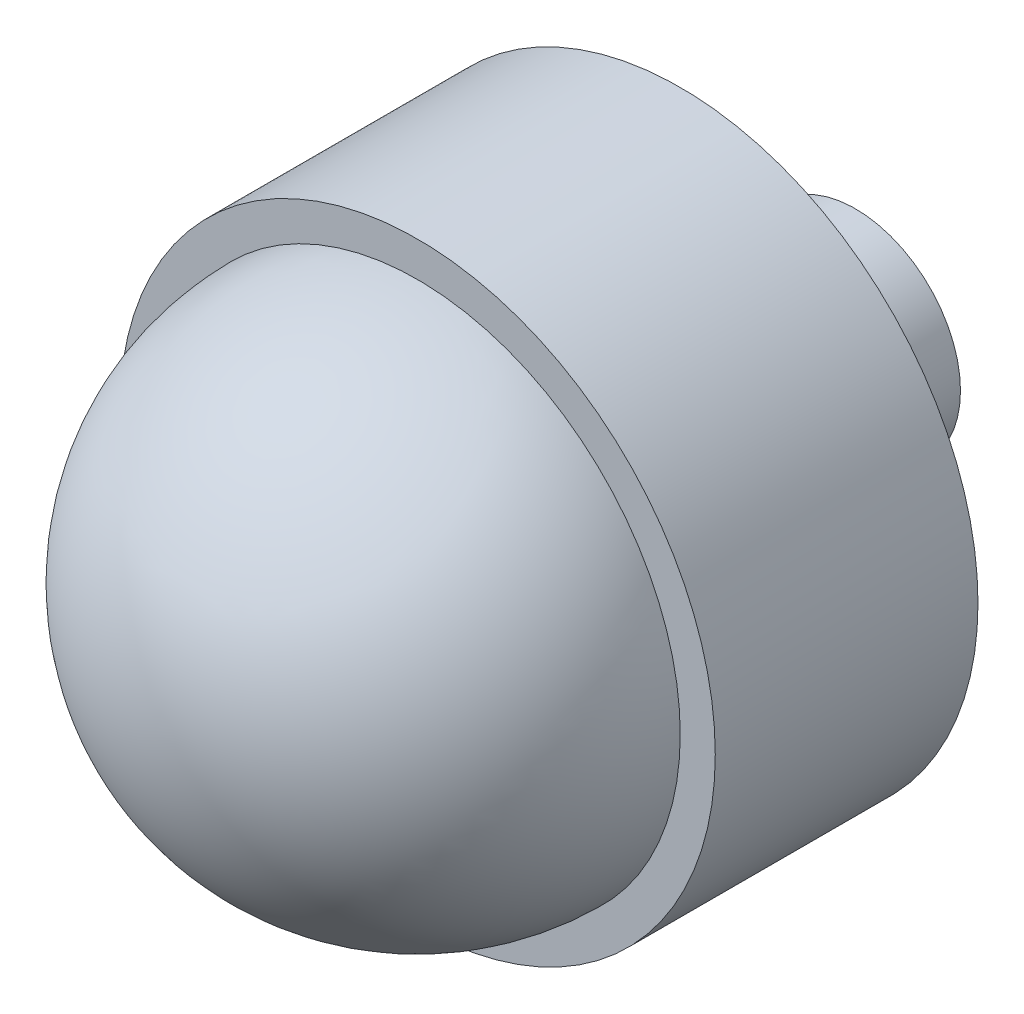
from build123d import *


with BuildPart() as part:
    # Sketch1 → Revolve6 (revolve)
    with BuildSketch(Plane(origin=(0, 0, 0), x_dir=(1, 0, 0), z_dir=(0, 1, 0))):
        with BuildLine():
            Line((0, 73.69930834), (6, 73.69930834))
            Line((6, 73.69930834), (6, 63.69930834))
            Line((6, 63.69930834), (17, 63.69930834))
            Line((17, 63.69930834), (17, 48.69930834))
            Line((17, 48.69930834), (15, 48.69930834))
            ThreePointArc((15, 48.69930834), (10.606601718, 38.092706622), (0, 33.69930834))
            Line((0, 33.69930834), (0, 73.69930834))
        make_face()
    revolve(axis=Axis((0, 0, 0), (0, 0, -1)))


solid = part.part
